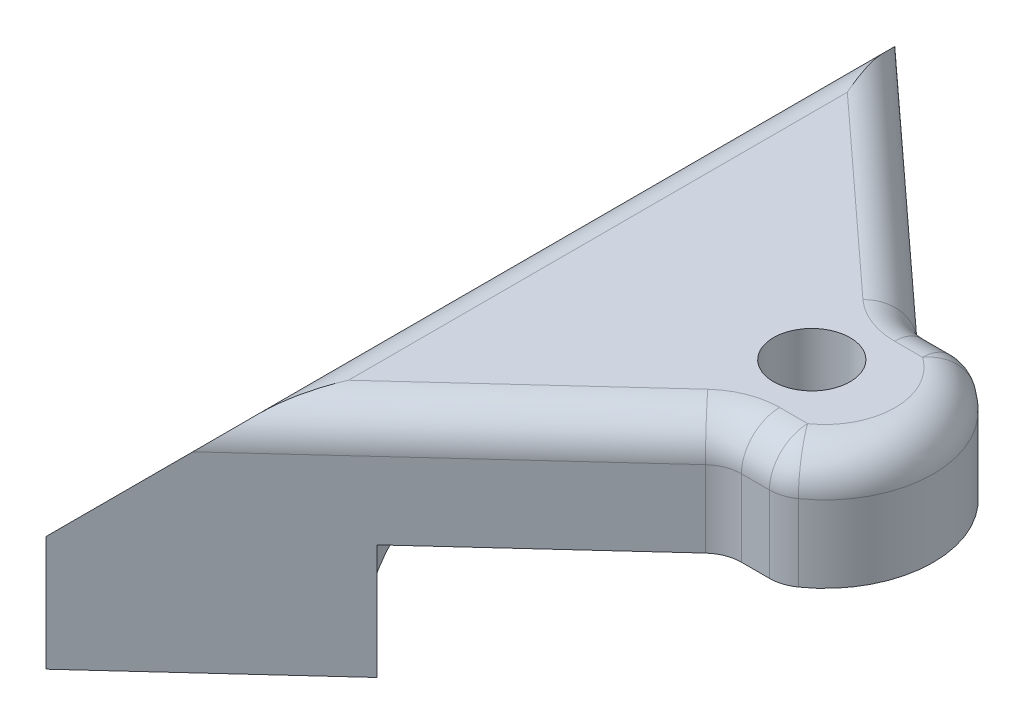
from build123d import *

# Parameters (mm, degrees)
BOSS_EXTRUDE1_DEPTH = 15
SKETCH2_W           = 21
SKETCH2_H           = 8
SKETCH2_W_2         = 17
SKETCH2_H_2         = 17
CUT_EXTRUDE2_DEPTH  = 6
SKETCH3_R           = 5
CUT_EXTRUDE3_DEPTH  = 10
BOSS_EXTRUDE3_DEPTH = 15
SKETCH5_R           = 3.5
BOSS_EXTRUDE4_DEPTH = 4
CHAMFER1_SIZE       = 15
FILLET1_R           = 5


with BuildPart() as part:
    # Sketch1 → Boss-Extrude1 (new body)
    with BuildSketch(Plane(origin=(0, 0, 0), x_dir=(1, 0, 0), z_dir=(0, 1, 0))):
        with BuildLine():
            Line((-6, -26.842412903), (40.363636364, 15.657587097))
            Line((40.363636364, 15.657587097), (47.363636364, 15.657587097))
            ThreePointArc((47.363636364, 15.657587097), (54.863636364, 28.157587097), (47.363636364, 40.657587097))
            Line((47.363636364, 40.657587097), (40.363636364, 40.657587097))
            Line((40.363636364, 40.657587097), (-6, 83.157587097))
            Line((-6, 83.157587097), (-6, -26.842412903))
        make_face()
    extrude(amount=BOSS_EXTRUDE1_DEPTH)

    # Sketch2 → Cut-Extrude2 (cut)
    with BuildSketch(Plane.XZ):
        with Locations((20, -28.157587097)):
            Rectangle(SKETCH2_W, SKETCH2_H)
        with Locations((39, -28.157587097)):
            Rectangle(SKETCH2_W_2, SKETCH2_H_2)
    extrude(amount=-CUT_EXTRUDE2_DEPTH, mode=Mode.SUBTRACT)

    # Sketch3 → Cut-Extrude3 (cut, through all)
    with BuildSketch(Plane(origin=(0, 6, 0), x_dir=(-1, 0, 0), z_dir=(0, 1, 0))):
        with Locations((-39, -28.157587097)):
            Circle(SKETCH3_R)
    extrude(amount=CUT_EXTRUDE3_DEPTH, mode=Mode.SUBTRACT)

    # Sketch6 → Boss-Extrude3 (add)
    with BuildSketch(Plane.XZ):
        with BuildLine():
            Line((-6, 26.842412903), (-6, -83.157587097))
            Line((-6, -83.157587097), (16.563859252, -62.474049449))
            ThreePointArc((16.563859252, -62.474049449), (-2, -28.157587097), (16.563859252, 6.158875255))
            Line((16.563859252, 6.158875255), (-6, 26.842412903))
        make_face()
    extrude(amount=BOSS_EXTRUDE3_DEPTH)

    # Sketch5 → Boss-Extrude4 (add)
    with BuildSketch(Plane.ZY.offset(6)):
        with Locations((-53.157587097, -8)):
            Circle(SKETCH5_R)
        with Locations((-3.157587097, -8)):
            Circle(SKETCH5_R)
    extrude(amount=BOSS_EXTRUDE4_DEPTH)

    # Chamfer1
    chamfer1_edges = [part.edges().sort_by_distance(p)[0] for p in [
        (-6, 15, -28.157587097),
    ]]
    chamfer(chamfer1_edges, length=CHAMFER1_SIZE)

    # Fillet1
    fillet1_edges = [part.edges().sort_by_distance(p)[0] for p in [
        (43.863636364, 15, -40.657587097),
        (47.363636364, 7.5, -15.657587097),
        (40.363636364, 7.5, -15.657587097),
        (40.363636364, 7.5, -40.657587097),
        (47.363636364, 7.5, -40.657587097),
        (24.681818182, 15, -55.032587097),
        (43.863636364, 15, -15.657587097),
        (54.863636364, 15, -28.157587097),
        (24.681818182, 15, -1.282587097),
        (9, 15, -28.157587097),
    ]]
    fillet(fillet1_edges, radius=FILLET1_R)


solid = part.part
